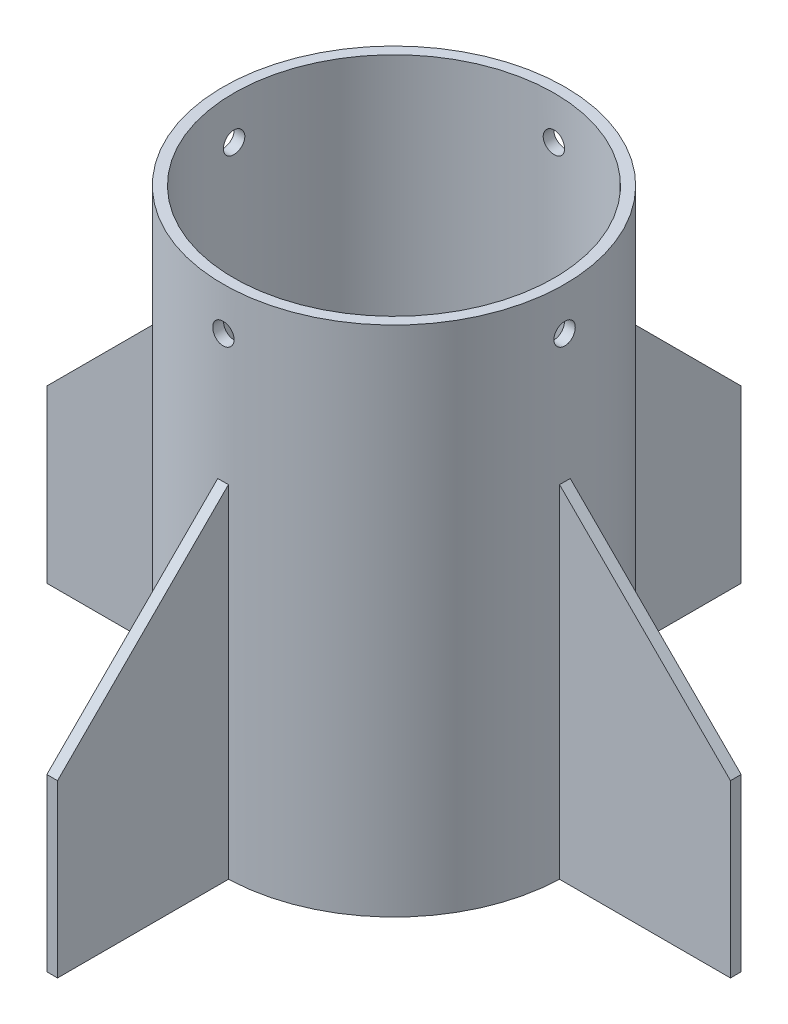
from build123d import *

# Parameters (mm, degrees)
SKETCH2_R               = 6.35
CUT_EXTRUDE1_DEPTH      = 305.8
BOSS_EXTRUDE1_DEPTH     = 3.175
BOSS_EXTRUDE1_2_DEPTH   = 3.175
BOSS_EXTRUDE3_DEPTH     = 3.175
BOSS_EXTRUDE3_2_DEPTH   = 3.175
SKETCH5_R               = 6.35
CUT_EXTRUDE2_DEPTH      = 204.2
CUT_EXTRUDE2_DEPTH_BACK = 204.2
SKETCH6_R               = 6.35
CUT_EXTRUDE3_DEPTH      = 204.2
CUT_EXTRUDE3_DEPTH_BACK = 204.2


with BuildPart() as part:
    # Sketch1 → Revolve1 (revolve)
    with BuildSketch(Plane.XY):
        Polygon((95.25, 6.35), (95.25, 304.8), (101.6, 304.8), (101.6, 0), (69.85, 0), (69.85, 6.35), align=None)
    revolve(axis=Axis((0, 0, 0), (0, 1, 0)))

    # Sketch2 → Cut-Extrude1 (cut, through all)
    with BuildSketch(Plane.XZ):
        with Locations((0, 82.55)):
            Circle(SKETCH2_R)
        with Locations((41.275, 71.490397082)):
            Circle(SKETCH2_R)
        with Locations((71.490397082, 41.275)):
            Circle(SKETCH2_R)
        with Locations((82.55, 0)):
            Circle(SKETCH2_R)
        with Locations((71.490397082, -41.275)):
            Circle(SKETCH2_R)
        with Locations((41.275, -71.490397082)):
            Circle(SKETCH2_R)
        with Locations((0, -82.55)):
            Circle(SKETCH2_R)
        with Locations((-41.275, -71.490397082)):
            Circle(SKETCH2_R)
        with Locations((-71.490397082, -41.275)):
            Circle(SKETCH2_R)
        with Locations((-82.55, 0)):
            Circle(SKETCH2_R)
        with Locations((-71.490397082, 41.275)):
            Circle(SKETCH2_R)
        with Locations((-41.275, 71.490397082)):
            Circle(SKETCH2_R)
    extrude(amount=-CUT_EXTRUDE1_DEPTH, mode=Mode.SUBTRACT)

    # Sketch5 → Cut-Extrude2 (cut, two sides)
    with BuildSketch(Plane.XY) as cut_extrude2_sk:
        with Locations((0, 279.4)):
            Circle(SKETCH5_R)
    extrude(amount=CUT_EXTRUDE2_DEPTH, mode=Mode.SUBTRACT)
    extrude(cut_extrude2_sk.sketch, amount=-CUT_EXTRUDE2_DEPTH_BACK, mode=Mode.SUBTRACT)

    # Sketch6 → Cut-Extrude3 (cut, two sides)
    with BuildSketch(Plane(origin=(0, 0, 0), x_dir=(0, 0, -1), z_dir=(1, 0, 0))) as cut_extrude3_sk:
        with Locations((0, 279.4)):
            Circle(SKETCH6_R)
    extrude(amount=CUT_EXTRUDE3_DEPTH, mode=Mode.SUBTRACT)
    extrude(cut_extrude3_sk.sketch, amount=-CUT_EXTRUDE3_DEPTH_BACK, mode=Mode.SUBTRACT)


with BuildPart() as body_2:
    # Sketch3 → Boss-Extrude1 (new body, symmetric)
    with BuildSketch(Plane.XY):
        Polygon((-101.6, 0), (-203.2, 0), (-203.2, 101.6), (-101.6, 203.2), align=None)
    extrude(amount=BOSS_EXTRUDE1_DEPTH, both=True)


with BuildPart() as body_3:
    # Sketch3 → Boss-Extrude1 2 (new body, symmetric)
    with BuildSketch(Plane.XY):
        Polygon((203.2, 101.6), (101.6, 203.2), (101.6, 0), (203.2, 0), align=None)
    extrude(amount=BOSS_EXTRUDE1_2_DEPTH, both=True)


with BuildPart() as body_4:
    # Sketch4 → Boss-Extrude3 (new body, symmetric)
    with BuildSketch(Plane(origin=(0, 0, 0), x_dir=(0, 0, -1), z_dir=(1, 0, 0))):
        Polygon((-101.6, 0), (-203.2, 0), (-203.2, 101.6), (-101.6, 203.2), align=None)
    extrude(amount=BOSS_EXTRUDE3_DEPTH, both=True)


with BuildPart() as body_5:
    # Sketch4 → Boss-Extrude3 2 (new body, symmetric)
    with BuildSketch(Plane(origin=(0, 0, 0), x_dir=(0, 0, -1), z_dir=(1, 0, 0))):
        Polygon((203.2, 101.6), (101.6, 203.2), (101.6, 0), (203.2, 0), align=None)
    extrude(amount=BOSS_EXTRUDE3_2_DEPTH, both=True)


solid = Compound([part.part, body_2.part, body_3.part, body_4.part, body_5.part])
